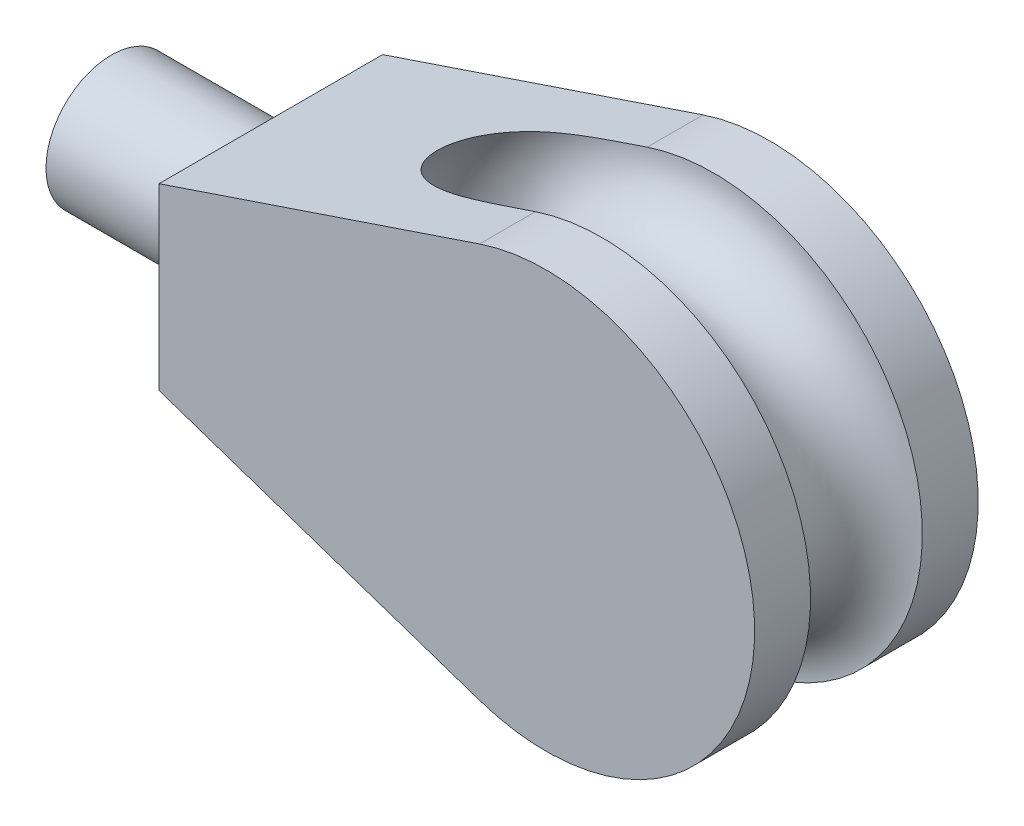
from build123d import *

# Parameters (mm, degrees)
BOSS_EXTRUDE1_DEPTH = 7.9248
SKETCH2_R           = 4.6355
BOSS_EXTRUDE2_DEPTH = 11.303
SKETCH6_R           = 3.9624


with BuildPart() as part:
    # Sketch1 → Boss-Extrude1 (new body, symmetric)
    with BuildSketch(Plane.XY):
        with BuildLine():
            Line((-27.441594764, 6.35), (-27.441594764, -6.35))
            Line((-27.441594764, -6.35), (-4.72195802, -14.00836494))
            ThreePointArc((-4.72195802, -14.00836494), (14.7828, 0), (-4.72195802, 14.00836494))
            Line((-4.72195802, 14.00836494), (-27.441594764, 6.35))
        make_face()
    extrude(amount=BOSS_EXTRUDE1_DEPTH, both=True)

    # Sketch2 → Boss-Extrude2 (add)
    with BuildSketch(Plane.ZY.offset(27.441594764)):
        Circle(SKETCH2_R)
    extrude(amount=BOSS_EXTRUDE2_DEPTH)

    # Sketch6 → Cut-Revolve1 (revolve, cut)
    with BuildSketch(Plane(origin=(0, 0, 0), x_dir=(0, 0, -1), z_dir=(1, 0, 0))):
        with Locations((0, 14.7828)):
            Circle(SKETCH6_R)
    revolve(axis=Axis((0, 0, 0), (0, 0, -1)), mode=Mode.SUBTRACT)


solid = part.part
